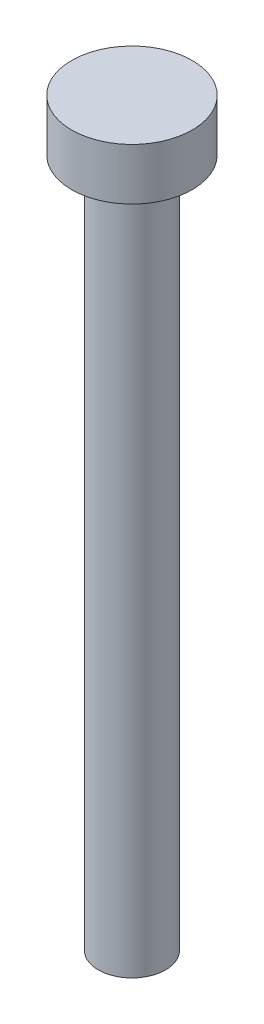
from build123d import *

# Parameters (mm, degrees)
SKETCH1_R           = 3.5
BOSS_EXTRUDE1_DEPTH = 3
SKETCH2_R           = 1.95
BOSS_EXTRUDE2_DEPTH = 40


with BuildPart() as part:
    # Sketch1 → Boss-Extrude1 (new body)
    with BuildSketch(Plane(origin=(0, 0, 0), x_dir=(1, 0, 0), z_dir=(0, 1, 0))):
        Circle(SKETCH1_R)
    extrude(amount=BOSS_EXTRUDE1_DEPTH)

    # Sketch2 → Boss-Extrude2 (add)
    with BuildSketch(Plane.XZ):
        Circle(SKETCH2_R)
    extrude(amount=BOSS_EXTRUDE2_DEPTH)


solid = part.part
